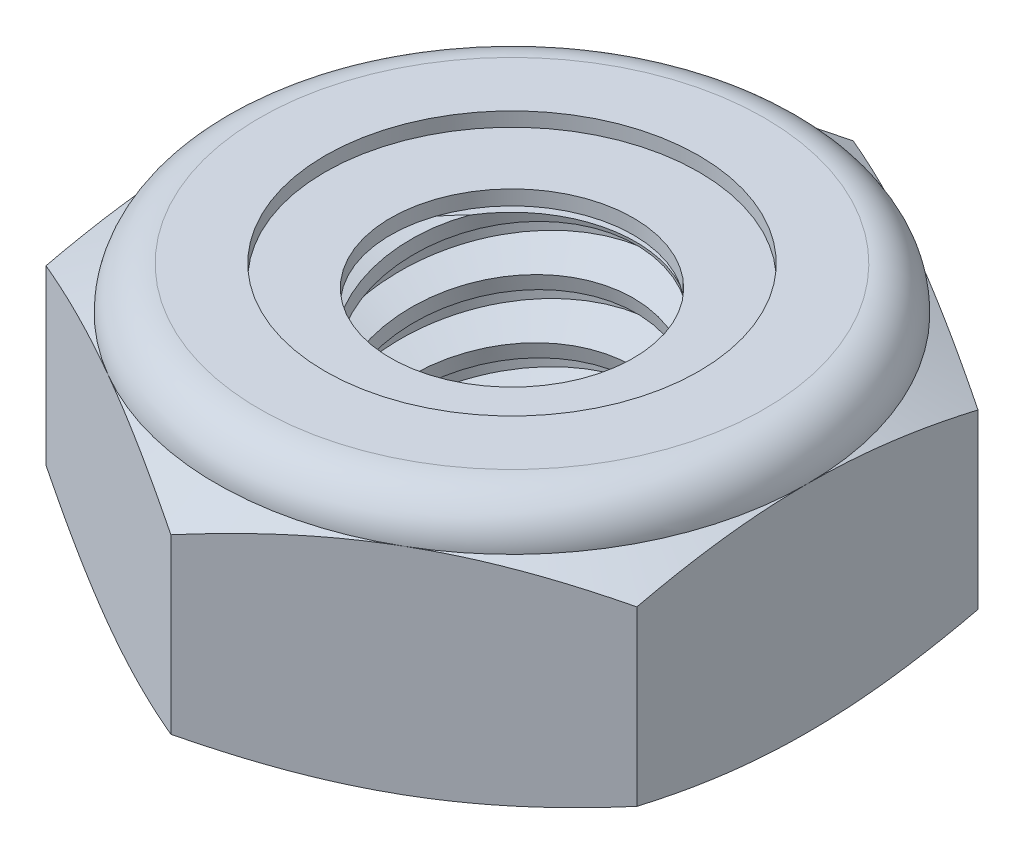
from build123d import *

# Parameters (mm, degrees)
EXTRUDE1_DEPTH      = 2.778125
SKETCH2_W           = 1.5875
SKETCH2_H           = 2.778125
LPATTERN1_COUNT     = 4
LPATTERN1_PITCH     = 0.635
LPATTERN1_COL_COUNT = 2
LPATTERN1_COL_PITCH = 0.635


with BuildPart() as part:
    # Sketch1 → Extrude1 (new body)
    with BuildSketch(Plane(origin=(0, 0, 0), x_dir=(1, 0, 0), z_dir=(0, 1, 0))):
        Polygon((0, 3.666174209), (-3.175, 1.833087105), (-3.175, -1.833087105), (0, -3.666174209), (3.175, -1.833087105), (3.175, 1.833087105), align=None)
    extrude(amount=EXTRUDE1_DEPTH)

    # Sketch4 → Cut-Revolve2 (revolve, cut)
    with BuildSketch(Plane(origin=(0, 0, 0), x_dir=(0, 0, -1), z_dir=(1, 0, 0))):
        Polygon((0, 2.778125), (1.5875, 2.778125), (1.304954178, 2.646371719), (1.304954178, 0.131753281), (1.5875, 0), (0, 0), align=None)
    revolve(axis=Axis((0, 2.778125, 0), (0, 1, 0)), mode=Mode.SUBTRACT)


with BuildPart() as body_2:
    # Sketch2 → Revolve1 (revolve)
    with BuildSketch(Plane(origin=(0, 0, 0), x_dir=(0, 0, -1), z_dir=(1, 0, 0))):
        with Locations((0.79375, 1.3890625)):
            Rectangle(SKETCH2_W, SKETCH2_H)
    revolve(axis=Axis((0, -1.5875, 0), (0, 1, 0)))

    # Sketch3 → Cut-Revolve1 (revolve, cut)
    with BuildSketch(Plane(origin=(0, 0, 0), x_dir=(0, 0, -1), z_dir=(1, 0, 0))):
        Polygon((1.603066718, 2.700291409), (1.712033746, 2.155456271), (1.336087614, 2.282634382), (1.304954178, 2.438301564), align=None)
    cut_revolve1 = revolve(axis=Axis((0, 2.778125, 0.136352241), (0, -0.980580676, -0.196116135)), mode=Mode.SUBTRACT)

    # LPattern1: Cut-Revolve1 ×4
    with Locations(*[(0, -i * LPATTERN1_PITCH, 0) for i in range(1, LPATTERN1_COUNT)]):
        add(cut_revolve1, mode=Mode.SUBTRACT)

    # LPattern1 col: Cut-Revolve1 ×2
    with Locations(*[(0, i * LPATTERN1_COL_PITCH, 0) for i in range(1, LPATTERN1_COL_COUNT)]):
        add(cut_revolve1, mode=Mode.SUBTRACT)


with BuildPart() as part_1:
    add(part.part)

    # Combine1: cut body 2
    add(body_2.part, mode=Mode.SUBTRACT)

    # Sketch5 → Cut-Revolve3 (revolve, cut)
    with BuildSketch(Plane(origin=(0, 0, 0), x_dir=(0, 0, -1), z_dir=(1, 0, 0))):
        with BuildLine():
            Line((0, 0), (3.175, 0))
            Line((3.175, 0), (3.666174209, 0.229038295))
            Line((3.666174209, 0.229038295), (3.666174209, 2.086065871))
            Line((3.666174209, 2.086065871), (3.175, 2.315104167))
            ThreePointArc((3.175, 2.315104167), (3.039384338, 2.642509338), (2.711979167, 2.778125))
            Line((2.711979167, 2.778125), (2.711979167, 4.048125))
            Line((2.711979167, 4.048125), (4.936174209, 4.048125))
            Line((4.936174209, 4.048125), (4.936174209, -1.27))
            Line((4.936174209, -1.27), (0, -1.27))
            Line((0, -1.27), (0, 0))
        make_face()
    revolve(axis=Axis((0, 0, 0), (0, 1, 0)), mode=Mode.SUBTRACT)

    # Sketch6 → Cut-Revolve4 (revolve, cut)
    with BuildSketch(Plane(origin=(0, 0, 0), x_dir=(0, 0, -1), z_dir=(1, 0, 0))):
        with BuildLine():
            Line((0, 2.315104167), (3.0226, 2.315104167))
            ThreePointArc((3.0226, 2.315104167), (2.931621264, 2.534746264), (2.711979167, 2.625725))
            Line((2.711979167, 2.625725), (2.008466672, 2.625725))
            Line((2.008466672, 2.625725), (2.008466672, 4.048125))
            Line((2.008466672, 4.048125), (0, 4.048125))
            Line((0, 4.048125), (0, 2.315104167))
        make_face()
    revolve(axis=Axis((0, 4.048125, 0), (0, 1, 0)), mode=Mode.SUBTRACT)


with BuildPart() as body_2_2:
    # Sketch7 → Revolve2 (revolve)
    with BuildSketch(Plane(origin=(0, 0, 0), x_dir=(0, 0, -1), z_dir=(1, 0, 0))):
        with BuildLine():
            Line((1.304954178, 2.391304167), (2.933669688, 2.391304167))
            ThreePointArc((2.933669688, 2.391304167), (2.848159671, 2.505912964), (2.711979167, 2.549525))
            Line((2.711979167, 2.549525), (1.304954178, 2.549525))
            Line((1.304954178, 2.549525), (1.304954178, 2.391304167))
        make_face()
    revolve(axis=Axis((0, 2.391304167, 0), (0, 1, 0)))


solid = Compound([part_1.part, body_2_2.part])
